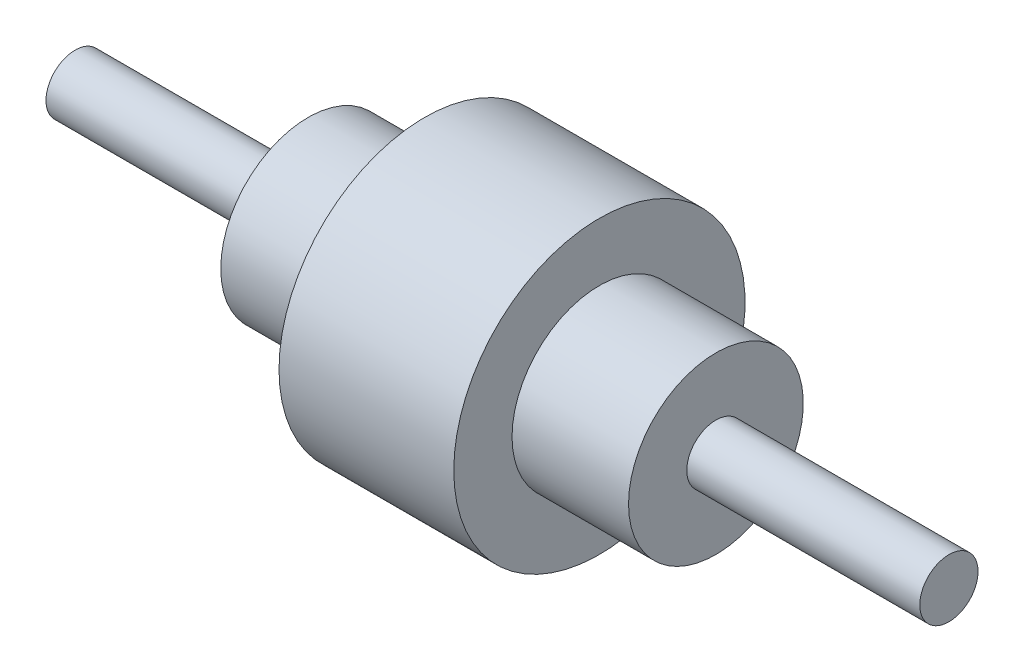
from build123d import *

# Parameters (mm, degrees)
SKETCH1_W = 80
SKETCH1_H = 10


with BuildPart() as part:
    # Sketch1 → Revolve1 (revolve)
    with BuildSketch(Plane.XY, mode=Mode.PRIVATE) as revolve1_sk:
        with Locations((40, 5)):
            Rectangle(SKETCH1_W, SKETCH1_H)
        Polygon((80, 10), (80, 0), (120, 0), (120, 30), (80, 30), align=None)
        Polygon((120, 30), (120, 0), (180, 0), (180, 30), (180, 50), (120, 50), align=None)
        Polygon((180, 30), (180, 0), (220, 0), (220, 10), (220, 30), align=None)
        with Locations((260, 5)):
            Rectangle(SKETCH1_W, SKETCH1_H)
    revolve(revolve1_sk.sketch.rotate(Axis((0, 0, 0), (1, 0, 0)), 90), axis=Axis((0, 0, 0), (1, 0, 0)))  # turned: the seam where the file's is


solid = part.part
